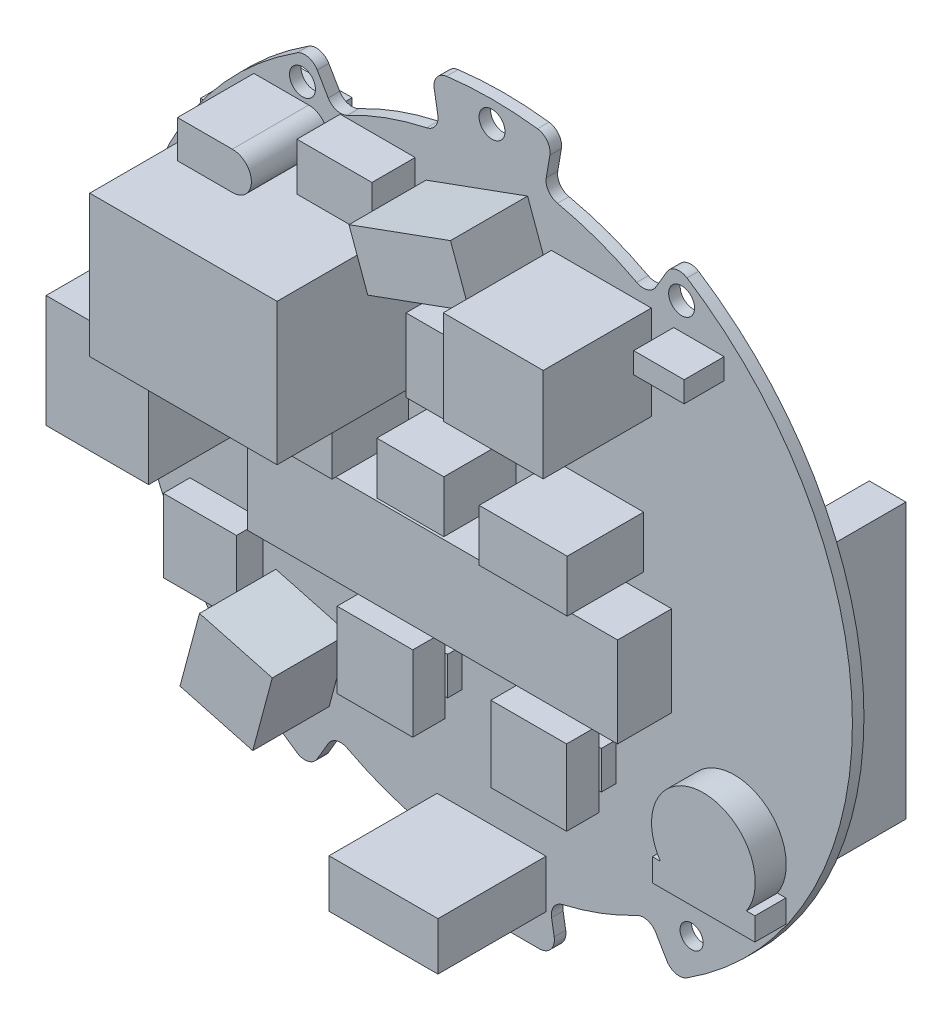
from build123d import *

# Parameters (mm, degrees)
BOSS_EXTRUDE1_DEPTH  = 1.6
SKETCH11_R           = 1.6
SKETCH11_R_2         = 1.2
SKETCH11_R_3         = 1.8
CUT_EXTRUDE1_DEPTH   = 2.6
SKETCH12_W           = 25.993421387
SKETCH12_H           = 19.638455677
BOSS_EXTRUDE2_DEPTH  = 20
SKETCH14_W           = 5.08001016
SKETCH14_H           = 38.1000762
BOSS_EXTRUDE4_DEPTH  = 12
SKETCH15_W           = 13.861010922
SKETCH15_H           = 13.035534671
BOSS_EXTRUDE5_DEPTH  = 15
SKETCH16_W           = 14.224028448
SKETCH16_H           = 15.621031242
BOSS_EXTRUDE6_DEPTH  = 15
SKETCH17_W           = 15.113030226
SKETCH17_H           = 6.668986538
BOSS_EXTRUDE7_DEPTH  = 15
BOSS_EXTRUDE8_DEPTH  = 10.7
SKETCH19_W           = 10.4000508
SKETCH19_H           = 6.604013208
BOSS_EXTRUDE9_DEPTH  = 6
BOSS_EXTRUDE10_DEPTH = 10.6
SKETCH21_W           = 12.3500127
SKETCH21_H           = 7.198323596
SKETCH21_W_2         = 12.223012446
BOSS_EXTRUDE11_DEPTH = 10.6
SKETCH22_W           = 51.363576327
SKETCH22_H           = 12.498907798
BOSS_EXTRUDE12_DEPTH = 7.5
BOSS_EXTRUDE13_DEPTH = 10.6
SKETCH24_W           = 10.152400305
SKETCH24_H           = 10.152400304
BOSS_EXTRUDE14_DEPTH = 3.7
SKETCH25_W           = 9.299009398
SKETCH25_H           = 7.2
BOSS_EXTRUDE15_DEPTH = 10
SKETCH26_W           = 10.16002032
SKETCH26_H           = 10.16002032
BOSS_EXTRUDE16_DEPTH = 5.2
SKETCH27_W           = 7
SKETCH27_H           = 2.9000254
BOSS_EXTRUDE17_DEPTH = 5.55
BOSS_EXTRUDE18_DEPTH = 4.3
SKETCH30_W           = 10.452476505
SKETCH30_H           = 10.452476505
SKETCH30_H_2         = 10.453213107
BOSS_EXTRUDE19_DEPTH = 10.6
SKETCH31_W           = 7.1999492
SKETCH31_H           = 15.2000762
BOSS_EXTRUDE20_DEPTH = 4
SKETCH32_W           = 6
SKETCH32_H           = 5.999745999
BOSS_EXTRUDE21_DEPTH = 4.5
SKETCH33_W           = 11.152400304
SKETCH33_H           = 5.242824485
BOSS_EXTRUDE22_DEPTH = 2
SKETCH34_W           = 10.5
SKETCH34_H           = 10.5
BOSS_EXTRUDE24_DEPTH = 4.5
BOSS_EXTRUDE25_DEPTH = 3


with BuildPart() as part:
    # Sketch10 → Boss-Extrude1 (new body)
    with BuildSketch(Plane.XY):
        with BuildLine():
            Line((22.728600457, -39.998272797), (24.246786894, -42.589001778))
            ThreePointArc((24.246786894, -42.589001778), (25.507595239, -43.523063443), (27.054457709, -43.25976632))
            ThreePointArc((27.054457709, -43.25976632), (50.000017134, -1.211493523), (27.054457709, 40.836779274))
            ThreePointArc((27.054457709, 40.836779274), (25.507601077, 41.100087329), (24.246786894, 40.166040132))
            Line((24.246786894, 40.166040132), (22.728600457, 37.575311151))
            ThreePointArc((22.728600457, 37.575311151), (21.551080829, 36.662999435), (20.069545339, 36.817653035))
            ThreePointArc((20.069545339, 36.817653035), (14.706892219, 39.195291287), (9.070535941, 40.820929642))
            ThreePointArc((9.070535941, 40.820929642), (7.836209779, 41.65474739), (7.520574041, 43.110490221))
            Line((7.520574041, 43.110490221), (8.022860046, 46.070942342))
            ThreePointArc((8.022860046, 46.070942342), (7.657490258, 47.596976154), (6.303251207, 48.389636779))
            ThreePointArc((6.303251207, 48.389636779), (3.81e-05, 48.788532915), (-6.303175006, 48.389636779))
            ThreePointArc((-6.303175006, 48.389636779), (-7.657512722, 47.597025313), (-8.022936246, 46.070942342))
            Line((-8.022936246, 46.070942342), (-7.520523241, 43.110490221))
            ThreePointArc((-7.520523241, 43.110490221), (-7.836149553, 41.654754702), (-9.070459741, 40.820929642))
            ThreePointArc((-9.070459741, 40.820929642), (-14.706829, 39.19529293), (-20.069494539, 36.817653035))
            ThreePointArc((-20.069494539, 36.817653035), (-21.551030028, 36.662999435), (-22.728549657, 37.575311151))
            Line((-22.728549657, 37.575311151), (-24.246609093, 40.166040132))
            ThreePointArc((-24.246609093, 40.166040132), (-25.507477936, 41.10015142), (-27.054406909, 40.836779274))
            ThreePointArc((-27.054406909, 40.836779274), (-49.999966334, -1.211493523), (-27.054406909, -43.25976632))
            ThreePointArc((-27.054406909, -43.25976632), (-25.507472097, -43.523127534), (-24.246609093, -42.589001778))
            Line((-24.246609093, -42.589001778), (-22.728549657, -39.998272797))
            ThreePointArc((-22.728549657, -39.998272797), (-21.551035654, -39.085946522), (-20.069494539, -39.240589281))
            ThreePointArc((-20.069494539, -39.240589281), (-15.06123876, -41.487502712), (-9.807543815, -43.078079756))
            ThreePointArc((-9.807543815, -43.078079756), (-8.572234213, -43.936492535), (-8.25994412, -45.408001016))
            Line((-8.25994412, -45.408001016), (-8.623698247, -47.551358903))
            ThreePointArc((-8.623698247, -47.551358903), (-8.155986109, -49.263840958), (-6.545897892, -50.011480823))
            Line((-6.545897892, -50.011480823), (6.545923292, -50.011480823))
            ThreePointArc((6.545923292, -50.011480823), (8.155994304, -49.263831256), (8.623698247, -47.551358903))
            Line((8.623698247, -47.551358903), (8.25996952, -45.408001016))
            ThreePointArc((8.25996952, -45.408001016), (8.570031553, -43.939853248), (9.799720599, -43.07993396))
            ThreePointArc((9.799720599, -43.07993396), (15.057502517, -41.488924147), (20.069545339, -39.240589281))
            ThreePointArc((20.069545339, -39.240589281), (21.551086454, -39.085946522), (22.728600457, -39.998272797))
        make_face()
    extrude(amount=BOSS_EXTRUDE1_DEPTH)

    # Sketch11 → Cut-Extrude1 (cut, through all)
    with BuildSketch(Plane.XY.offset(1.6)):
        with Locations((27.683515367, -37.948437897)):
            Circle(SKETCH11_R)
        with Locations((-33.233934468, -34.445262891)):
            Circle(SKETCH11_R_2)
        with Locations((-27.683515367, -37.948437897)):
            Circle(SKETCH11_R)
        with Locations((26.3002286, 37.729235458)):
            Circle(SKETCH11_R_3)
        with Locations((0, 45.778511557)):
            Circle(SKETCH11_R_3)
        with Locations((-26.2999746, 37.729235458)):
            Circle(SKETCH11_R_3)
    extrude(amount=-CUT_EXTRUDE1_DEPTH, mode=Mode.SUBTRACT)

    # Sketch12 → Boss-Extrude2 (add)
    with BuildSketch(Plane.XY.offset(1.6)):
        with Locations((-22.817360935, 19.771805943)):
            Rectangle(SKETCH12_W, SKETCH12_H)
    extrude(amount=BOSS_EXTRUDE2_DEPTH)

    # Sketch14 → Boss-Extrude4 (add)
    with BuildSketch(Plane(origin=(0, 0, 0), x_dir=(-1, 0, 0), z_dir=(0, 0, -1))):
        with Locations((-41.27508255, -3.556007112)):
            Rectangle(SKETCH14_W, SKETCH14_H)
        with Locations((-23.49504699, -3.556007112)):
            Rectangle(SKETCH14_W, SKETCH14_H)
    extrude(amount=BOSS_EXTRUDE4_DEPTH)

    # Sketch15 → Boss-Extrude5 (add)
    with BuildSketch(Plane.XY.offset(1.6)):
        with Locations((15.167538735, 28.226174753)):
            Rectangle(SKETCH15_W, SKETCH15_H)
    extrude(amount=BOSS_EXTRUDE5_DEPTH)

    # Sketch16 → Boss-Extrude6 (add)
    with BuildSketch(Plane.XY.offset(1.6)):
        with Locations((-39.751079502, 1.460502921)):
            Rectangle(SKETCH16_W, SKETCH16_H)
    extrude(amount=BOSS_EXTRUDE6_DEPTH)

    # Sketch17 → Boss-Extrude7 (add)
    with BuildSketch(Plane.XY.offset(1.6)):
        with Locations((-0.063474727, -41.755600711)):
            Rectangle(SKETCH17_W, SKETCH17_H)
    extrude(amount=BOSS_EXTRUDE7_DEPTH)

    # Sketch18 → Boss-Extrude8 (add)
    with BuildSketch(Plane.XY.offset(1.6)):
        Polygon((-9.148412497, 34.487198374), (-6.542189484, 27.326695453), (7.54008128, 32.452222504), (4.933858268, 39.612700025), align=None)
    extrude(amount=BOSS_EXTRUDE8_DEPTH)

    # Sketch19 → Boss-Extrude9 (add)
    with BuildSketch(Plane.XY.offset(1.6)):
        with Locations((-15.86499873, 33.147193294)):
            Rectangle(SKETCH19_W, SKETCH19_H)
    extrude(amount=BOSS_EXTRUDE9_DEPTH)

    # Sketch20 → Boss-Extrude10 (add)
    with BuildSketch(Plane.XY.offset(1.6)):
        with BuildLine():
            Line((-33.03992888, 35.366065532), (-33.03992888, 30.166065532))
            Line((-33.03992888, 30.166065532), (-25.343205486, 30.166065532))
            ThreePointArc((-25.343205486, 30.166065532), (-22.788366777, 32.811633223), (-25.433934468, 35.366471933))
            Line((-25.433934468, 35.366471933), (-33.03992888, 35.366065532))
        make_face()
    extrude(amount=BOSS_EXTRUDE10_DEPTH)

    # Sketch21 → Boss-Extrude11 (add)
    with BuildSketch(Plane.XY.offset(1.6)):
        with Locations((-17.78003556, 6.223012446)):
            Rectangle(SKETCH21_W, SKETCH21_H)
        with Locations((14.922529845, 6.096012192)):
            Rectangle(SKETCH21_W_2, SKETCH21_H)
    extrude(amount=BOSS_EXTRUDE11_DEPTH)

    # Sketch22 → Boss-Extrude12 (add)
    with BuildSketch(Plane.XY.offset(1.6)):
        with Locations((-0.761264923, -6.222453645)):
            Rectangle(SKETCH22_W, SKETCH22_H)
    extrude(amount=BOSS_EXTRUDE12_DEPTH)

    # Sketch23 → Boss-Extrude13 (add)
    with BuildSketch(Plane.XY.offset(1.6)):
        Polygon((-32.68986538, -32.778562357), (-29.984558226, -22.682250802), (-25.979730759, -23.755346711), (-19.888250785, -25.387562404), (-22.593548387, -35.483870968), align=None)
    extrude(amount=BOSS_EXTRUDE13_DEPTH)

    # Sketch24 → Boss-Extrude14 (add)
    with BuildSketch(Plane.XY.offset(1.6)):
        with Locations((-36.830073661, -22.733045466)):
            Rectangle(SKETCH24_W, SKETCH24_H)
    extrude(amount=BOSS_EXTRUDE14_DEPTH)

    # Sketch25 → Boss-Extrude15 (add)
    with BuildSketch(Plane.XY.offset(1.6)):
        with Locations((-1.333502667, 6.477012954)):
            Rectangle(SKETCH25_W, SKETCH25_H)
    extrude(amount=BOSS_EXTRUDE15_DEPTH)

    # Sketch26 → Boss-Extrude16 (add)
    with BuildSketch(Plane.XY.offset(1.6)):
        with Locations((-1.651003302, 17.272034544)):
            Rectangle(SKETCH26_W, SKETCH26_H)
    extrude(amount=BOSS_EXTRUDE16_DEPTH)

    # Sketch27 → Boss-Extrude17 (add)
    with BuildSketch(Plane.XY.offset(1.6)):
        with Locations((28.702057404, 32.504089408)):
            Rectangle(SKETCH27_W, SKETCH27_H)
    extrude(amount=BOSS_EXTRUDE17_DEPTH)

    # Sketch28 → Boss-Extrude18 (add)
    with BuildSketch(Plane.XY.offset(1.6)):
        with BuildLine():
            Line((26.543053086, -29.953111506), (40.767081534, -29.953111506))
            Line((40.767081534, -29.953111506), (40.767081534, -26.797078994))
            Line((40.767081534, -26.797078994), (39.589068271, -26.797078994))
            ThreePointArc((39.589068271, -26.797078994), (33.623004382, -15.581450679), (27.656940493, -26.797078994))
            Line((27.656940493, -26.797078994), (26.543053086, -26.797078994))
            Line((26.543053086, -26.797078994), (26.543053086, -29.953111506))
        make_face()
    extrude(amount=BOSS_EXTRUDE18_DEPTH)

    # Sketch30 → Boss-Extrude19 (add)
    with BuildSketch(Plane(origin=(0, 0, 0), x_dir=(-1, 0, 0), z_dir=(0, 0, -1))):
        with Locations((36.830073661, 21.844043689)):
            Rectangle(SKETCH30_W, SKETCH30_H)
        with Locations((41.021082042, 11.302654306)):
            Rectangle(SKETCH30_W, SKETCH30_H_2)
    extrude(amount=BOSS_EXTRUDE19_DEPTH)

    # Sketch31 → Boss-Extrude20 (add)
    with BuildSketch(Plane(origin=(0, 0, 0), x_dir=(-1, 0, 0), z_dir=(0, 0, -1))):
        with Locations((41.656083312, -1.523990348)):
            Rectangle(SKETCH31_W, SKETCH31_H)
    extrude(amount=BOSS_EXTRUDE20_DEPTH)

    # Sketch32 → Boss-Extrude21 (add)
    with BuildSketch(Plane(origin=(0, 0, 0), x_dir=(-1, 0, 0), z_dir=(0, 0, -1))):
        with Locations((1.397129794, -43.434213869)):
            Rectangle(SKETCH32_W, SKETCH32_H)
    extrude(amount=BOSS_EXTRUDE21_DEPTH)

    # Sketch33 → Boss-Extrude22 (add)
    with BuildSketch(Plane.XY.offset(1.6)):
        with Locations((-9.746507493, -21.621666244)):
            Rectangle(SKETCH33_W, SKETCH33_H)
        with Locations((11.589535179, -22.256667514)):
            Rectangle(SKETCH33_W, SKETCH33_H)
    extrude(amount=BOSS_EXTRUDE22_DEPTH)

    # Sketch34 → Boss-Extrude24 (add)
    with BuildSketch(Plane.XY.offset(3.6)):
        with Locations((-9.746507493, -21.621666243)):
            Rectangle(SKETCH34_W, SKETCH34_H)
        with Locations((11.589535179, -22.256667513)):
            Rectangle(SKETCH34_W, SKETCH34_H)
    extrude(amount=BOSS_EXTRUDE24_DEPTH)

    # Sketch35 → Boss-Extrude25 (add)
    with BuildSketch(Plane(origin=(0, 0, 0), x_dir=(-1, 0, 0), z_dir=(0, 0, -1))):
        with BuildLine():
            Line((-15.893599187, -37.45501651), (32.106299213, -37.45501651))
            ThreePointArc((32.106299213, -37.45501651), (34.581044141, -36.42997516), (35.606121412, -33.95524511))
            Line((35.606121412, -33.95524511), (35.606121412, -0.955270511))
            ThreePointArc((35.606121412, -0.955270511), (34.53805394, 1.463874579), (32.093954788, 2.473533147))
            Line((32.093954788, 2.473533147), (-15.905943612, 2.473533147))
            ThreePointArc((-15.905943612, 2.473533147), (-18.381210976, 1.448710695), (-19.405943612, -1.026593853))
            Line((-19.405943612, -1.026593853), (-19.393548387, -33.95524511))
            ThreePointArc((-19.393548387, -33.95524511), (-18.368374139, -36.429967985), (-15.893599187, -37.45501651))
        make_face()
    extrude(amount=BOSS_EXTRUDE25_DEPTH)


solid = part.part
